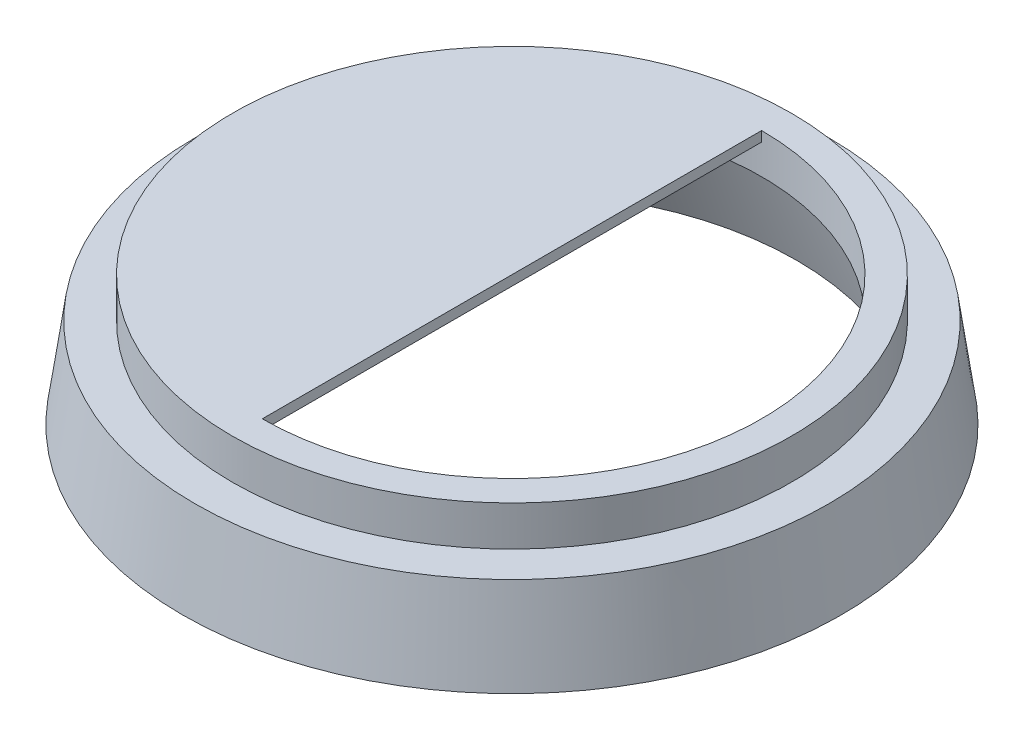
from build123d import *

# Parameters (mm, degrees)
SKETCH1_R           = 16.5
BOSS_EXTRUDE1_DEPTH = 6.5
BOSS_EXTRUDE1_TAPER = 8
SKETCH2_R           = 14.25
CUT_EXTRUDE1_DEPTH  = 4.5
CUT_EXTRUDE1_TAPER  = 21
CUT_EXTRUDE2_DEPTH  = 6
CHAMFER1_SIZE       = 1.5
SKETCH4_R           = 17.295094409
SKETCH4_R_2         = 14
CUT_EXTRUDE3_DEPTH  = 2


with BuildPart() as part:
    # Sketch1 → Boss-Extrude1 (new body)
    with BuildSketch(Plane(origin=(0, 0, 0), x_dir=(1, 0, 0), z_dir=(0, 1, 0))):
        Circle(SKETCH1_R)
    extrude(amount=BOSS_EXTRUDE1_DEPTH, taper=BOSS_EXTRUDE1_TAPER)

    # Sketch2 → Cut-Extrude1 (cut)
    with BuildSketch(Plane.XZ):
        Circle(SKETCH2_R)
    extrude(amount=-CUT_EXTRUDE1_DEPTH, taper=CUT_EXTRUDE1_TAPER, mode=Mode.SUBTRACT)

    # Sketch3 → Cut-Extrude2 (cut)
    with BuildSketch(Plane(origin=(0, 6.5, 0), x_dir=(1, 0, 0), z_dir=(0, 1, 0))):
        with BuildLine():
            Line((0, -12.5), (0, 12.5))
            ThreePointArc((0, 12.5), (12.5, 0), (0, -12.5))
        make_face()
    extrude(amount=-CUT_EXTRUDE2_DEPTH, mode=Mode.SUBTRACT)

    # Chamfer1
    chamfer1_edges = [part.edges().sort_by_distance(p)[0] for p in [
        (0, 4.5, 0),
    ]]
    chamfer(chamfer1_edges, length=CHAMFER1_SIZE)

    # Sketch4 → Cut-Extrude3 (cut)
    with BuildSketch(Plane(origin=(0, 6.5, 0), x_dir=(1, 0, 0), z_dir=(0, 1, 0))):
        Circle(SKETCH4_R)
        Circle(SKETCH4_R_2, mode=Mode.SUBTRACT)
    extrude(amount=-CUT_EXTRUDE3_DEPTH, mode=Mode.SUBTRACT)


solid = part.part
